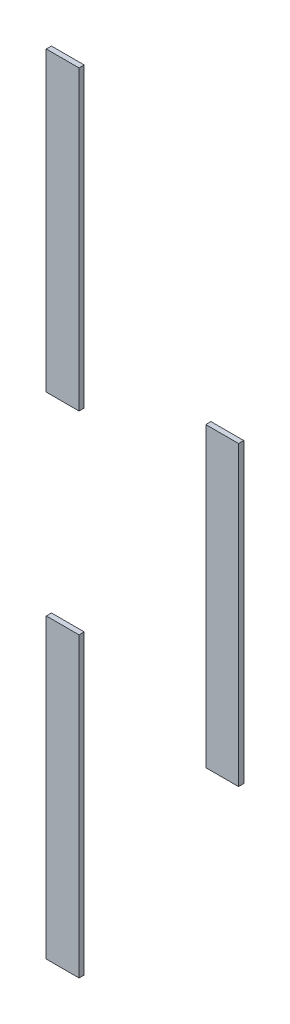
from build123d import *

# Parameters (mm, degrees)
SKETCH1_W             = 12.7
SKETCH1_H             = 115
BOSS_EXTRUDE1_DEPTH   = 2
BOSS_EXTRUDE1_2_DEPTH = 2
BOSS_EXTRUDE1_3_DEPTH = 2


with BuildPart() as part:
    # Sketch1 → Boss-Extrude1 (new body)
    with BuildSketch(Plane.XY):
        with Locations((-30.578112918, 47.5)):
            Rectangle(SKETCH1_W, SKETCH1_H)
    extrude(amount=BOSS_EXTRUDE1_DEPTH)


with BuildPart() as body_2:
    # Sketch1 → Boss-Extrude1 2 (new body)
    with BuildSketch(Plane.XY):
        with Locations((31.153379131, 142.5)):
            Rectangle(SKETCH1_W, SKETCH1_H)
    extrude(amount=BOSS_EXTRUDE1_2_DEPTH)


with BuildPart() as body_3:
    # Sketch1 → Boss-Extrude1 3 (new body)
    with BuildSketch(Plane.XY):
        with Locations((-30.578112918, 237.5)):
            Rectangle(SKETCH1_W, SKETCH1_H)
    extrude(amount=BOSS_EXTRUDE1_3_DEPTH)


solid = Compound([part.part, body_2.part, body_3.part])
